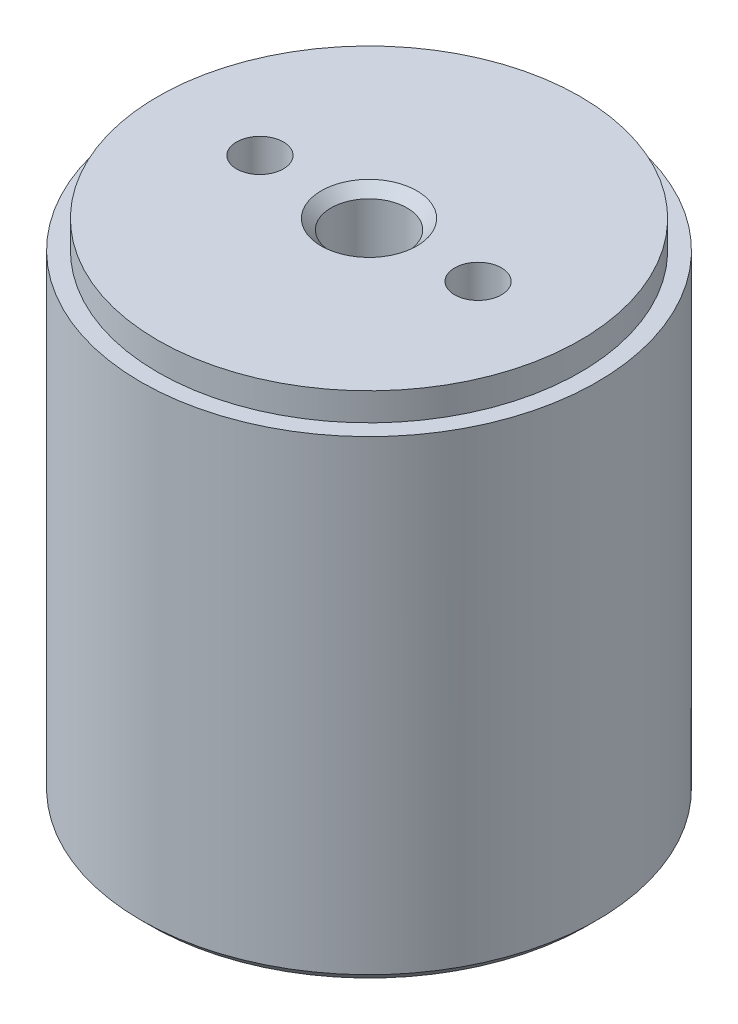
from build123d import *

# Parameters (mm, degrees)
SKETCH2_R                  = 10.65
BOSS_EXTRUDE1_DEPTH        = 1.4
M2_CLEARANCE_HOLE1_D       = 2.362
M2_CLEARANCE_HOLE1_DEPTH   = 5
M2_CLEARANCE_HOLE2_D       = 2.362
M2_CLEARANCE_HOLE2_DEPTH   = 9
M3_5_CLEARANCE_HOLE1_D     = 3.83
M3_5_CLEARANCE_HOLE1_DEPTH = 5
M2_CLEARANCE_HOLE3_D       = 2.362
M2_CLEARANCE_HOLE3_DEPTH   = 5
CHAMFER1_SIZE              = 0.498


with BuildPart() as part:
    # Sketch1 → Revolve1 (revolve)
    with BuildSketch(Plane(origin=(0, 0, 0), x_dir=(-1, 0, 0), z_dir=(0, 0, -1))):
        with BuildLine():
            Line((-2.413, -4), (0, -4))
            Line((0, -4), (0, 24))
            Line((0, 24), (-11.5, 24))
            Line((-11.5, 24), (-11.5, 0))
            Line((-11.5, 0), (-8.835106781, 0))
            ThreePointArc((-8.835106781, 0), (-8.128, -0.5), (-7.420893219, 0))
            Line((-7.420893219, 0), (-3.602106781, 0))
            ThreePointArc((-3.602106781, 0), (-3.092512244, -0.473525337), (-2.413, -0.324609433))
            Line((-2.413, -0.324609433), (-2.413, -4))
        make_face()
    revolve(axis=Axis((0, -4, 0), (0, 1, 0)))

    # Sketch2 → Boss-Extrude1 (add)
    with BuildSketch(Plane(origin=(0, 24, 0), x_dir=(-1, 0, 0), z_dir=(0, 1, 0))):
        Circle(SKETCH2_R)
    extrude(amount=BOSS_EXTRUDE1_DEPTH)

    # M2 Clearance Hole1
    with Locations(Plane(origin=(0, 0, 0), x_dir=(-1, 0, 0), z_dir=(0, -1, 0))):
        with Locations((-5.5, 0), (5.5, 0)):
            Hole(M2_CLEARANCE_HOLE1_D / 2, depth=M2_CLEARANCE_HOLE1_DEPTH)

    # M2 Clearance Hole2
    with Locations(Plane(origin=(0, -4, 0), x_dir=(-1, 0, 0), z_dir=(0, -1, 0))):
        with Locations((0, 0)):
            Hole(M2_CLEARANCE_HOLE2_D / 2, depth=M2_CLEARANCE_HOLE2_DEPTH)

    # M3.5 Clearance Hole1
    with Locations(Plane(origin=(0, 25.4, 0), x_dir=(1, 0, 0), z_dir=(0, 1, 0))):
        with Locations((0, 0)):
            Hole(M3_5_CLEARANCE_HOLE1_D / 2, depth=M3_5_CLEARANCE_HOLE1_DEPTH)

    # M2 Clearance Hole3
    with Locations(Plane(origin=(0, 25.4, 0), x_dir=(1, 0, 0), z_dir=(0, 1, 0))):
        with Locations((5.5, 0), (-5.5, 0)):
            Hole(M2_CLEARANCE_HOLE3_D / 2, depth=M2_CLEARANCE_HOLE3_DEPTH)

    # Chamfer1
    chamfer1_edges = [part.edges().sort_by_distance(p)[0] for p in [
        (-2.413, -4, 0),
        (1.915, 25.4, 0),
        (-11.5, 0, 0),
    ]]
    chamfer(chamfer1_edges, length=CHAMFER1_SIZE)


solid = part.part
